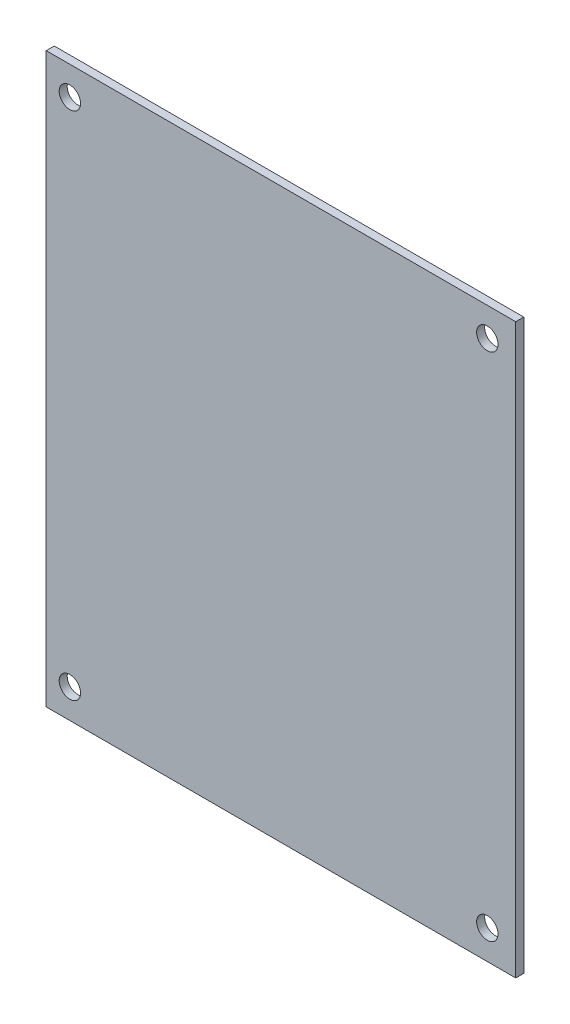
from build123d import *

# Parameters (mm, degrees)
SKETCH1_W           = 87.72
SKETCH1_H           = 106.2
BOSS_EXTRUDE1_DEPTH = 1.5
SKETCH2_R           = 2
CUT_EXTRUDE1_DEPTH  = 2.5


with BuildPart() as part:
    # Sketch1 → Boss-Extrude1 (new body)
    with BuildSketch(Plane.XY):
        with Locations((43.86, 53.1)):
            Rectangle(SKETCH1_W, SKETCH1_H)
    extrude(amount=BOSS_EXTRUDE1_DEPTH)

    # Sketch2 → Cut-Extrude1 (cut, through all)
    with BuildSketch(Plane.XY.offset(1.5)):
        with Locations((4.413201005, 100.851121267)):
            Circle(SKETCH2_R)
        with Locations((4.413201005, 5.451121267)):
            Circle(SKETCH2_R)
        with Locations((82.413201005, 100.851121267)):
            Circle(SKETCH2_R)
        with Locations((82.413201005, 5.451121267)):
            Circle(SKETCH2_R)
    extrude(amount=-CUT_EXTRUDE1_DEPTH, mode=Mode.SUBTRACT)


solid = part.part
